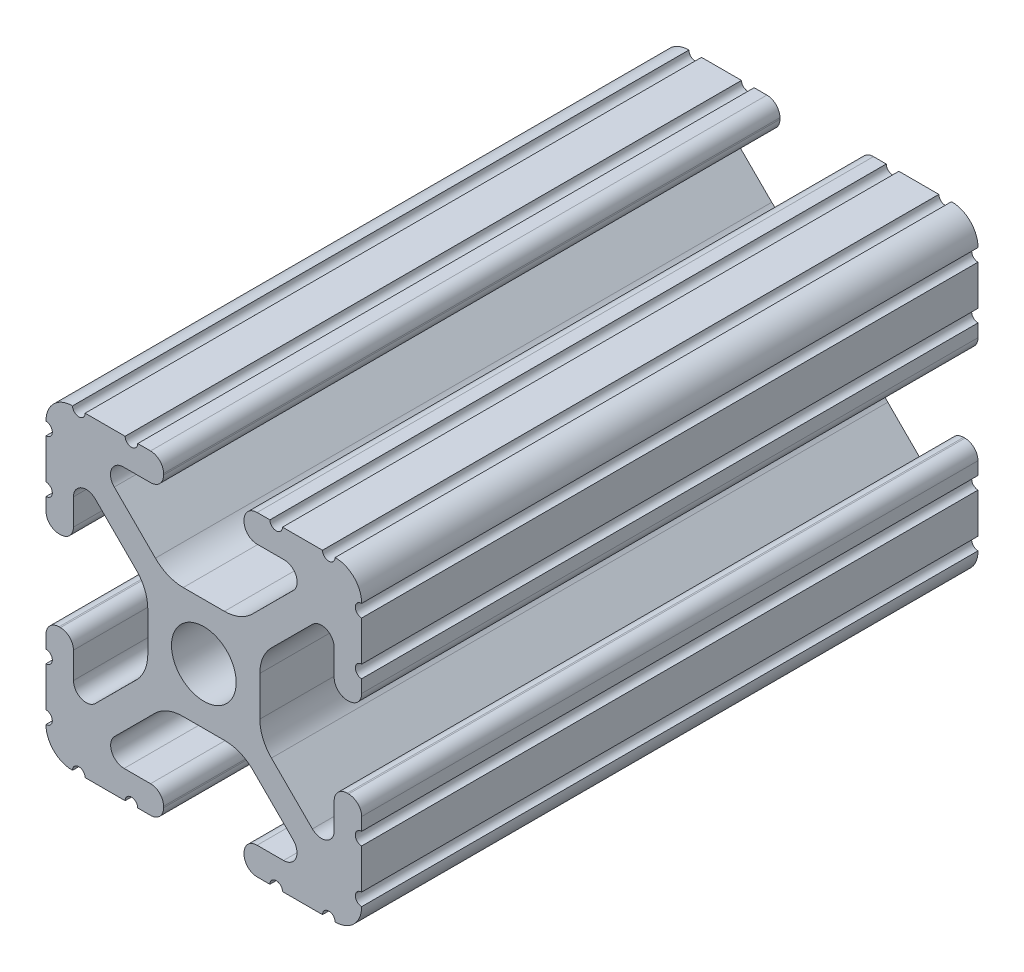
from build123d import *

# Parameters (mm, degrees)
SKETCH1_R           = 2.6035
BOSS_EXTRUDE1_DEPTH = 24.8


with BuildPart() as part:
    # Sketch1 → Boss-Extrude1 (new body, symmetric)
    with BuildSketch(Plane.XY):
        with BuildLine():
            Line((-7.179650497, -8.645192506), (-3.952270251, -5.423690499))
            ThreePointArc((-3.952270251, -5.423690499), (-2.922936451, -4.736929036), (-1.709253557, -4.4958))
            Line((-1.709253557, -4.4958), (1.709253557, -4.4958))
            ThreePointArc((1.709253557, -4.4958), (2.922936451, -4.736929036), (3.952270251, -5.423690499))
            Line((3.952270251, -5.423690499), (7.179650497, -8.645192506))
            ThreePointArc((7.179650497, -8.645192506), (7.41473083, -9.822813117), (6.416408329, -10.4902))
            Line((6.416408329, -10.4902), (4.287512407, -10.4902))
            ThreePointArc((4.287512407, -10.4902), (3.54574862, -10.79744862), (3.2385, -11.539212407))
            Line((3.2385, -11.539212407), (3.2385, -11.650987593))
            ThreePointArc((3.2385, -11.650987593), (3.54574862, -12.39275138), (4.287512407, -12.7))
            Line((4.287512407, -12.7), (5.317126718, -12.7))
            ThreePointArc((5.317126718, -12.7), (5.825126718, -12.192), (6.333126718, -12.7))
            Line((6.333126718, -12.7), (9.550443118, -12.7))
            ThreePointArc((9.550443118, -12.7), (10.058366869, -12.192000006), (10.566443095, -12.699847501))
            ThreePointArc((10.566443095, -12.699847501), (12.082537762, -12.08250727), (12.699846982, -10.566399977))
            ThreePointArc((12.699846982, -10.566399977), (12.192000006, -10.058323491), (12.7, -9.5504))
            Line((12.7, -9.5504), (12.7, -6.3330836))
            ThreePointArc((12.7, -6.3330836), (12.192, -5.8250836), (12.7, -5.3170836))
            Line((12.7, -5.3170836), (12.7, -4.287469289))
            ThreePointArc((12.7, -4.287469289), (12.39275138, -3.545705502), (11.650987593, -3.238456882))
            Line((11.650987593, -3.238456882), (11.539212407, -3.238456882))
            ThreePointArc((11.539212407, -3.238456882), (10.79744862, -3.545705502), (10.4902, -4.287469289))
            Line((10.4902, -4.287469289), (10.4902, -6.402089023))
            ThreePointArc((10.4902, -6.402089023), (9.856505071, -7.351067942), (8.737131347, -7.129408934))
            Line((8.737131347, -7.129408934), (5.441005833, -3.840816462))
            ThreePointArc((5.441005833, -3.840816462), (4.750877967, -2.809883091), (4.5085, -1.593185507))
            Line((4.5085, -1.593185507), (4.5085, 1.593185507))
            ThreePointArc((4.5085, 1.593185507), (4.750877967, 2.809883091), (5.441005833, 3.840816462))
            Line((5.441005833, 3.840816462), (8.737131347, 7.129408934))
            ThreePointArc((8.737131347, 7.129408934), (9.856505071, 7.351067942), (10.4902, 6.402089023))
            Line((10.4902, 6.402089023), (10.4902, 4.287469289))
            ThreePointArc((10.4902, 4.287469289), (10.79744862, 3.545705502), (11.539212407, 3.238456882))
            Line((11.539212407, 3.238456882), (11.650987593, 3.238456882))
            ThreePointArc((11.650987593, 3.238456882), (12.39275138, 3.545705502), (12.7, 4.287469289))
            Line((12.7, 4.287469289), (12.7, 5.3170836))
            ThreePointArc((12.7, 5.3170836), (12.192, 5.8250836), (12.7, 6.3330836))
            Line((12.7, 6.3330836), (12.7, 9.5504))
            ThreePointArc((12.7, 9.5504), (12.192000006, 10.058323491), (12.699846982, 10.566399977))
            ThreePointArc((12.699846982, 10.566399977), (12.082537762, 12.08250727), (10.566443095, 12.699847501))
            ThreePointArc((10.566443095, 12.699847501), (10.058366869, 12.192000006), (9.550443118, 12.7))
            Line((9.550443118, 12.7), (6.333126718, 12.7))
            ThreePointArc((6.333126718, 12.7), (5.825126718, 12.192), (5.317126718, 12.7))
            Line((5.317126718, 12.7), (4.287512407, 12.7))
            ThreePointArc((4.287512407, 12.7), (3.54574862, 12.39275138), (3.2385, 11.650987593))
            Line((3.2385, 11.650987593), (3.2385, 11.539212407))
            ThreePointArc((3.2385, 11.539212407), (3.54574862, 10.79744862), (4.287512407, 10.4902))
            Line((4.287512407, 10.4902), (6.476788598, 10.4902))
            ThreePointArc((6.476788598, 10.4902), (7.432222385, 9.85140422), (7.207036008, 8.724370562))
            Line((7.207036008, 8.724370562), (3.898272566, 5.423169045))
            ThreePointArc((3.898272566, 5.423169045), (2.869120213, 4.736787962), (1.655778399, 4.4958))
            Line((1.655778399, 4.4958), (-1.655778399, 4.4958))
            ThreePointArc((-1.655778399, 4.4958), (-2.869120213, 4.736787962), (-3.898272566, 5.423169045))
            Line((-3.898272566, 5.423169045), (-7.207036008, 8.724370562))
            ThreePointArc((-7.207036008, 8.724370562), (-7.432222385, 9.85140422), (-6.476788598, 10.4902))
            Line((-6.476788598, 10.4902), (-4.287512407, 10.4902))
            ThreePointArc((-4.287512407, 10.4902), (-3.54574862, 10.79744862), (-3.2385, 11.539212407))
            Line((-3.2385, 11.539212407), (-3.2385, 11.650987593))
            ThreePointArc((-3.2385, 11.650987593), (-3.54574862, 12.39275138), (-4.287512407, 12.7))
            Line((-4.287512407, 12.7), (-5.317126718, 12.7))
            ThreePointArc((-5.317126718, 12.7), (-5.825126718, 12.192), (-6.333126718, 12.7))
            Line((-6.333126718, 12.7), (-9.550443118, 12.7))
            ThreePointArc((-9.550443118, 12.7), (-10.058366869, 12.192000006), (-10.566443095, 12.699847501))
            ThreePointArc((-10.566443095, 12.699847501), (-12.082537762, 12.08250727), (-12.699846982, 10.566399977))
            ThreePointArc((-12.699846982, 10.566399977), (-12.192000006, 10.058323491), (-12.7, 9.5504))
            Line((-12.7, 9.5504), (-12.7, 6.3330836))
            ThreePointArc((-12.7, 6.3330836), (-12.192, 5.8250836), (-12.7, 5.3170836))
            Line((-12.7, 5.3170836), (-12.7, 4.287469289))
            ThreePointArc((-12.7, 4.287469289), (-12.39275138, 3.545705502), (-11.650987593, 3.238456882))
            Line((-11.650987593, 3.238456882), (-11.539212407, 3.238456882))
            ThreePointArc((-11.539212407, 3.238456882), (-10.79744862, 3.545705502), (-10.4902, 4.287469289))
            Line((-10.4902, 4.287469289), (-10.4902, 6.402089023))
            ThreePointArc((-10.4902, 6.402089023), (-9.856505071, 7.351067942), (-8.737131347, 7.129408934))
            Line((-8.737131347, 7.129408934), (-5.441005833, 3.840816462))
            ThreePointArc((-5.441005833, 3.840816462), (-4.750877967, 2.809883091), (-4.5085, 1.593185507))
            Line((-4.5085, 1.593185507), (-4.5085, -1.593185507))
            ThreePointArc((-4.5085, -1.593185507), (-4.750877967, -2.809883091), (-5.441005833, -3.840816462))
            Line((-5.441005833, -3.840816462), (-8.737131347, -7.129408934))
            ThreePointArc((-8.737131347, -7.129408934), (-9.856505071, -7.351067942), (-10.4902, -6.402089023))
            Line((-10.4902, -6.402089023), (-10.4902, -4.287469289))
            ThreePointArc((-10.4902, -4.287469289), (-10.79744862, -3.545705502), (-11.539212407, -3.238456882))
            Line((-11.539212407, -3.238456882), (-11.650987593, -3.238456882))
            ThreePointArc((-11.650987593, -3.238456882), (-12.39275138, -3.545705502), (-12.7, -4.287469289))
            Line((-12.7, -4.287469289), (-12.7, -5.3170836))
            ThreePointArc((-12.7, -5.3170836), (-12.192, -5.8250836), (-12.7, -6.3330836))
            Line((-12.7, -6.3330836), (-12.7, -9.5504))
            ThreePointArc((-12.7, -9.5504), (-12.192000006, -10.058323491), (-12.699846982, -10.566399977))
            ThreePointArc((-12.699846982, -10.566399977), (-12.082537762, -12.08250727), (-10.566443095, -12.699847501))
            ThreePointArc((-10.566443095, -12.699847501), (-10.058366869, -12.192000006), (-9.550443118, -12.7))
            Line((-9.550443118, -12.7), (-6.333126718, -12.7))
            ThreePointArc((-6.333126718, -12.7), (-5.825126718, -12.192), (-5.317126718, -12.7))
            Line((-5.317126718, -12.7), (-4.287512407, -12.7))
            ThreePointArc((-4.287512407, -12.7), (-3.54574862, -12.39275138), (-3.2385, -11.650987593))
            Line((-3.2385, -11.650987593), (-3.2385, -11.539212407))
            ThreePointArc((-3.2385, -11.539212407), (-3.54574862, -10.79744862), (-4.287512407, -10.4902))
            Line((-4.287512407, -10.4902), (-6.416408329, -10.4902))
            ThreePointArc((-6.416408329, -10.4902), (-7.41473083, -9.822813117), (-7.179650497, -8.645192506))
        make_face()
        Circle(SKETCH1_R, mode=Mode.SUBTRACT)
    extrude(amount=BOSS_EXTRUDE1_DEPTH, both=True)


solid = part.part
